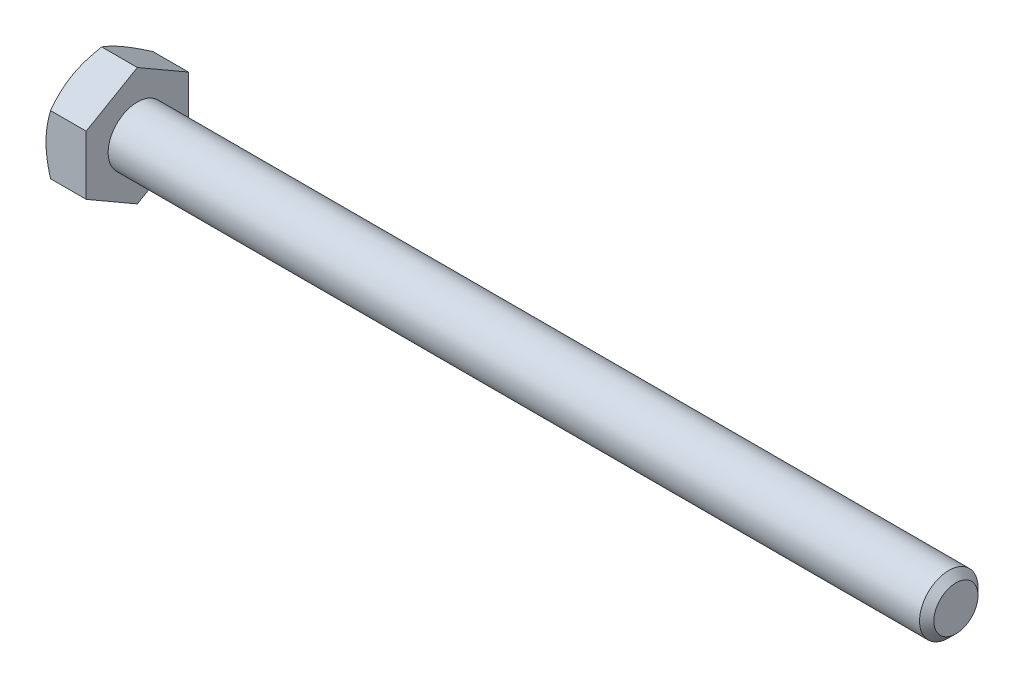
from build123d import *

# Parameters (mm, degrees)
SKETCH5_R           = 3.175
BOSS_EXTRUDE3_DEPTH = 88.9
CHAMFER1_SIZE       = 0.77724
BOSS_EXTRUDE4_DEPTH = 4.365625
SKETCH8_OUTSIDE_W   = 358.618
SKETCH8_OUTSIDE_H   = 360.338
SKETCH8_OUTSIDE_R   = 5.55625
CUT_EXTRUDE3_DEPTH  = 94.265625
CUT_EXTRUDE3_TAPER  = 60
CUT_EXTRUDE4_DEPTH  = 0.254
CIRPATTERN1_COUNT   = 3


with BuildPart() as part:
    # Sketch5 → Boss-Extrude3 (new body)
    with BuildSketch(Plane(origin=(46.6328125, 0, 0), x_dir=(0, 0, -1), z_dir=(1, 0, 0))):
        Circle(SKETCH5_R)
    extrude(amount=-BOSS_EXTRUDE3_DEPTH)

    # Chamfer1
    chamfer1_edges = [part.edges().sort_by_distance(p)[0] for p in [
        (46.6328125, 0, 3.175),
    ]]
    chamfer(chamfer1_edges, length=CHAMFER1_SIZE)

    # Sketch6 → Boss-Extrude4 (add)
    with BuildSketch(Plane.ZY.offset(42.2671875)):
        Polygon((5.55625, 3.207902433), (0, 6.415804866), (-5.55625, 3.207902433), (-5.55625, -3.207902433), (0, -6.415804866), (5.55625, -3.207902433), align=None)
    extrude(amount=BOSS_EXTRUDE4_DEPTH)

    # Sketch8 outside → Cut-Extrude3 (cut, through all)
    with BuildSketch(Plane.ZY.offset(46.6328125)):
        Rectangle(SKETCH8_OUTSIDE_W, SKETCH8_OUTSIDE_H)
        Circle(SKETCH8_OUTSIDE_R, mode=Mode.SUBTRACT)
    extrude(amount=-CUT_EXTRUDE3_DEPTH, taper=CUT_EXTRUDE3_TAPER, mode=Mode.SUBTRACT)

    # Sketch12 → Cut-Extrude4 (cut)
    with BuildSketch(Plane.ZY.offset(46.6328125)):
        with BuildLine():
            Line((0.1666875, 4.2783125), (0.1666875, 2.3891875))
            ThreePointArc((0.1666875, 2.3891875), (0, 2.2225), (-0.1666875, 2.3891875))
            Line((-0.1666875, 2.3891875), (-0.1666875, 4.2783125))
            ThreePointArc((-0.1666875, 4.2783125), (0, 4.445), (0.1666875, 4.2783125))
        make_face()
    cut_extrude4 = extrude(amount=-CUT_EXTRUDE4_DEPTH, mode=Mode.SUBTRACT)

    # CirPattern1: Cut-Extrude4 ×3 about axis
    cirpattern1_axis = Axis((0, 0, 0), (1, 0, 0))
    for i in range(1, CIRPATTERN1_COUNT):
        add(cut_extrude4.rotate(cirpattern1_axis, i * 360 / CIRPATTERN1_COUNT), mode=Mode.SUBTRACT)


solid = part.part
